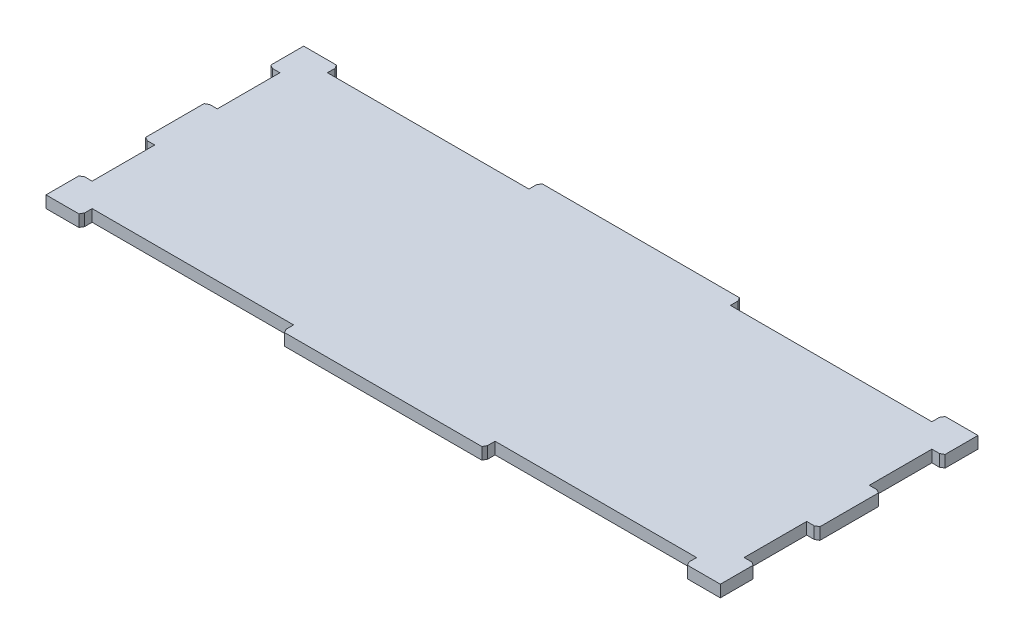
from build123d import *

# Parameters (mm, degrees)
SKETCH1_W             = 245.11
SKETCH1_H             = 93.653112922
BOSS_EXTRUDE1_DEPTH   = 4.318
CUT_EXTRUDE1_REACH    = 6.318
SKETCH2_W             = 4.064
SKETCH2_H             = 22.751037641
SKETCH2_W_2           = 73.236666667
SKETCH2_H_2           = 4.064
CHAMFER1_SIZE         = 0.762
CHAMFER1_SIZE2        = 1.319822715
CHAMFER1_PART_2_SIZE  = 0.762
CHAMFER1_PART_2_SIZE2 = 1.319822715
CHAMFER1_PART_3_SIZE  = 0.762
CHAMFER1_PART_3_SIZE2 = 1.319822715
CHAMFER1_PART_4_SIZE  = 0.762
CHAMFER1_PART_4_SIZE2 = 1.319822715
CHAMFER1_PART_5_SIZE  = 0.762
CHAMFER1_PART_5_SIZE2 = 1.319822715
CHAMFER1_PART_6_SIZE  = 0.762
CHAMFER1_PART_6_SIZE2 = 1.319822715
CHAMFER1_PART_7_SIZE  = 0.762
CHAMFER1_PART_7_SIZE2 = 1.319822715
CHAMFER1_PART_8_SIZE  = 0.762
CHAMFER1_PART_8_SIZE2 = 1.319822715
CHAMFER2_SIZE         = 0.762
CHAMFER2_SIZE2        = 1.319822715
CHAMFER2_PART_2_SIZE  = 0.762
CHAMFER2_PART_2_SIZE2 = 1.319822715
CHAMFER2_PART_3_SIZE  = 0.762
CHAMFER2_PART_3_SIZE2 = 1.319822715
CHAMFER2_PART_4_SIZE  = 0.762
CHAMFER2_PART_4_SIZE2 = 1.319822715
CHAMFER2_PART_5_SIZE  = 0.762
CHAMFER2_PART_5_SIZE2 = 1.319822715
CHAMFER2_PART_6_SIZE  = 0.762
CHAMFER2_PART_6_SIZE2 = 1.319822715
CHAMFER2_PART_7_SIZE  = 0.762
CHAMFER2_PART_7_SIZE2 = 1.319822715
CHAMFER2_PART_8_SIZE  = 0.762
CHAMFER2_PART_8_SIZE2 = 1.319822715


with BuildPart() as part:
    # Sketch1 → Boss-Extrude1 (new body)
    with BuildSketch(Plane(origin=(0, 0, 0), x_dir=(1, 0, 0), z_dir=(0, 1, 0))):
        Rectangle(SKETCH1_W, SKETCH1_H)
    extrude(amount=BOSS_EXTRUDE1_DEPTH)

    # Sketch2 → Cut-Extrude1 (cut, up to next)
    with BuildSketch(Plane(origin=(0, 4.318, 0), x_dir=(1, 0, 0), z_dir=(0, 1, 0)), mode=Mode.PRIVATE) as cut_extrude1_sk1:
        with Locations((-120.523, 22.751037641)):
            Rectangle(SKETCH2_W, SKETCH2_H)
    cut_extrude1_tool1 = extrude(cut_extrude1_sk1.sketch, amount=-CUT_EXTRUDE1_REACH, mode=Mode.PRIVATE) & part.part
    add(cut_extrude1_tool1.solids().sort_by_distance((-120.523, 4.318, -22.751038))[0], mode=Mode.SUBTRACT)
    # Sketch2 → Cut-Extrude1 (cut, up to next)
    with BuildSketch(Plane(origin=(0, 4.318, 0), x_dir=(1, 0, 0), z_dir=(0, 1, 0)), mode=Mode.PRIVATE) as cut_extrude1_sk2:
        with Locations((-73.236666666, -44.794556461)):
            Rectangle(SKETCH2_W_2, SKETCH2_H_2)
    cut_extrude1_tool2 = extrude(cut_extrude1_sk2.sketch, amount=-CUT_EXTRUDE1_REACH, mode=Mode.PRIVATE) & part.part
    add(cut_extrude1_tool2.solids().sort_by_distance((-73.236667, 4.318, 44.794556))[0], mode=Mode.SUBTRACT)
    # Sketch2 → Cut-Extrude1 (cut, up to next)
    with BuildSketch(Plane(origin=(0, 4.318, 0), x_dir=(1, 0, 0), z_dir=(0, 1, 0)), mode=Mode.PRIVATE) as cut_extrude1_sk3:
        with Locations((73.236666666, -44.794556461)):
            Rectangle(SKETCH2_W_2, SKETCH2_H_2)
    cut_extrude1_tool3 = extrude(cut_extrude1_sk3.sketch, amount=-CUT_EXTRUDE1_REACH, mode=Mode.PRIVATE) & part.part
    add(cut_extrude1_tool3.solids().sort_by_distance((73.236667, 4.318, 44.794556))[0], mode=Mode.SUBTRACT)
    # Sketch2 → Cut-Extrude1 (cut, up to next)
    with BuildSketch(Plane(origin=(0, 4.318, 0), x_dir=(1, 0, 0), z_dir=(0, 1, 0)), mode=Mode.PRIVATE) as cut_extrude1_sk4:
        with Locations((-120.523, -22.751037641)):
            Rectangle(SKETCH2_W, SKETCH2_H)
    cut_extrude1_tool4 = extrude(cut_extrude1_sk4.sketch, amount=-CUT_EXTRUDE1_REACH, mode=Mode.PRIVATE) & part.part
    add(cut_extrude1_tool4.solids().sort_by_distance((-120.523, 4.318, 22.751038))[0], mode=Mode.SUBTRACT)
    # Sketch2 → Cut-Extrude1 (cut, up to next)
    with BuildSketch(Plane(origin=(0, 4.318, 0), x_dir=(1, 0, 0), z_dir=(0, 1, 0)), mode=Mode.PRIVATE) as cut_extrude1_sk5:
        with Locations((-73.236666666, 44.794556461)):
            Rectangle(SKETCH2_W_2, SKETCH2_H_2)
    cut_extrude1_tool5 = extrude(cut_extrude1_sk5.sketch, amount=-CUT_EXTRUDE1_REACH, mode=Mode.PRIVATE) & part.part
    add(cut_extrude1_tool5.solids().sort_by_distance((-73.236667, 4.318, -44.794556))[0], mode=Mode.SUBTRACT)
    # Sketch2 → Cut-Extrude1 (cut, up to next)
    with BuildSketch(Plane(origin=(0, 4.318, 0), x_dir=(1, 0, 0), z_dir=(0, 1, 0)), mode=Mode.PRIVATE) as cut_extrude1_sk6:
        with Locations((73.236666666, 44.794556461)):
            Rectangle(SKETCH2_W_2, SKETCH2_H_2)
    cut_extrude1_tool6 = extrude(cut_extrude1_sk6.sketch, amount=-CUT_EXTRUDE1_REACH, mode=Mode.PRIVATE) & part.part
    add(cut_extrude1_tool6.solids().sort_by_distance((73.236667, 4.318, -44.794556))[0], mode=Mode.SUBTRACT)
    # Sketch2 → Cut-Extrude1 (cut, up to next)
    with BuildSketch(Plane(origin=(0, 4.318, 0), x_dir=(1, 0, 0), z_dir=(0, 1, 0)), mode=Mode.PRIVATE) as cut_extrude1_sk7:
        with Locations((120.523, 22.751037641)):
            Rectangle(SKETCH2_W, SKETCH2_H)
    cut_extrude1_tool7 = extrude(cut_extrude1_sk7.sketch, amount=-CUT_EXTRUDE1_REACH, mode=Mode.PRIVATE) & part.part
    add(cut_extrude1_tool7.solids().sort_by_distance((120.523, 4.318, -22.751038))[0], mode=Mode.SUBTRACT)
    # Sketch2 → Cut-Extrude1 (cut, up to next)
    with BuildSketch(Plane(origin=(0, 4.318, 0), x_dir=(1, 0, 0), z_dir=(0, 1, 0)), mode=Mode.PRIVATE) as cut_extrude1_sk8:
        with Locations((120.523, -22.751037641)):
            Rectangle(SKETCH2_W, SKETCH2_H)
    cut_extrude1_tool8 = extrude(cut_extrude1_sk8.sketch, amount=-CUT_EXTRUDE1_REACH, mode=Mode.PRIVATE) & part.part
    add(cut_extrude1_tool8.solids().sort_by_distance((120.523, 4.318, 22.751038))[0], mode=Mode.SUBTRACT)

    # Chamfer1
    chamfer1_edges = [part.edges().sort_by_distance(p)[0] for p in [
        (109.855, 2.159, -46.826556461),
    ]]
    chamfer1_side = [part.faces().sort_by_distance(p)[0] for p in [
        (116.205, 2.159, -46.826556461),
    ]]
    chamfer(chamfer1_edges, length=CHAMFER1_SIZE, length2=CHAMFER1_SIZE2, reference=chamfer1_side[0])

    # Chamfer1 part 2
    chamfer1_part_2_edges = [part.edges().sort_by_distance(p)[0] for p in [
        (-109.855, 2.159, 46.826556461),
    ]]
    chamfer1_part_2_side = [part.faces().sort_by_distance(p)[0] for p in [
        (-116.205, 2.159, 46.826556461),
    ]]
    chamfer(chamfer1_part_2_edges, length=CHAMFER1_PART_2_SIZE, length2=CHAMFER1_PART_2_SIZE2, reference=chamfer1_part_2_side[0])

    # Chamfer1 part 3
    chamfer1_part_3_edges = [part.edges().sort_by_distance(p)[0] for p in [
        (-36.618333333, 2.159, -46.826556461),
    ]]
    chamfer1_part_3_side = [part.faces().sort_by_distance(p)[0] for p in [
        (0, 2.159, -46.826556461),
    ]]
    chamfer(chamfer1_part_3_edges, length=CHAMFER1_PART_3_SIZE, length2=CHAMFER1_PART_3_SIZE2, reference=chamfer1_part_3_side[0])

    # Chamfer1 part 4
    chamfer1_part_4_edges = [part.edges().sort_by_distance(p)[0] for p in [
        (-122.555, 2.159, 11.37551882),
    ]]
    chamfer1_part_4_side = [part.faces().sort_by_distance(p)[0] for p in [
        (-122.555, 2.159, 0),
    ]]
    chamfer(chamfer1_part_4_edges, length=CHAMFER1_PART_4_SIZE, length2=CHAMFER1_PART_4_SIZE2, reference=chamfer1_part_4_side[0])

    # Chamfer1 part 5
    chamfer1_part_5_edges = [part.edges().sort_by_distance(p)[0] for p in [
        (122.555, 2.159, 34.126556461),
    ]]
    chamfer1_part_5_side = [part.faces().sort_by_distance(p)[0] for p in [
        (122.555, 2.159, 40.476556461),
    ]]
    chamfer(chamfer1_part_5_edges, length=CHAMFER1_PART_5_SIZE, length2=CHAMFER1_PART_5_SIZE2, reference=chamfer1_part_5_side[0])

    # Chamfer1 part 6
    chamfer1_part_6_edges = [part.edges().sort_by_distance(p)[0] for p in [
        (122.555, 2.159, -11.37551882),
    ]]
    chamfer1_part_6_side = [part.faces().sort_by_distance(p)[0] for p in [
        (122.555, 2.159, 0),
    ]]
    chamfer(chamfer1_part_6_edges, length=CHAMFER1_PART_6_SIZE, length2=CHAMFER1_PART_6_SIZE2, reference=chamfer1_part_6_side[0])

    # Chamfer1 part 7
    chamfer1_part_7_edges = [part.edges().sort_by_distance(p)[0] for p in [
        (36.618333333, 2.159, 46.826556461),
    ]]
    chamfer1_part_7_side = [part.faces().sort_by_distance(p)[0] for p in [
        (0, 2.159, 46.826556461),
    ]]
    chamfer(chamfer1_part_7_edges, length=CHAMFER1_PART_7_SIZE, length2=CHAMFER1_PART_7_SIZE2, reference=chamfer1_part_7_side[0])

    # Chamfer1 part 8
    chamfer1_part_8_edges = [part.edges().sort_by_distance(p)[0] for p in [
        (-122.555, 2.159, -34.126556461),
    ]]
    chamfer1_part_8_side = [part.faces().sort_by_distance(p)[0] for p in [
        (-122.555, 2.159, -40.476556461),
    ]]
    chamfer(chamfer1_part_8_edges, length=CHAMFER1_PART_8_SIZE, length2=CHAMFER1_PART_8_SIZE2, reference=chamfer1_part_8_side[0])

    # Chamfer2
    chamfer2_edges = [part.edges().sort_by_distance(p)[0] for p in [
        (36.618333333, 2.159, -46.826556461),
    ]]
    chamfer2_side = [part.faces().sort_by_distance(p)[0] for p in [
        (0.381, 2.159, -46.826556461),
    ]]
    chamfer(chamfer2_edges, length=CHAMFER2_SIZE, length2=CHAMFER2_SIZE2, reference=chamfer2_side[0])

    # Chamfer2 part 2
    chamfer2_part_2_edges = [part.edges().sort_by_distance(p)[0] for p in [
        (-36.618333333, 2.159, 46.826556461),
    ]]
    chamfer2_part_2_side = [part.faces().sort_by_distance(p)[0] for p in [
        (-0.381, 2.159, 46.826556461),
    ]]
    chamfer(chamfer2_part_2_edges, length=CHAMFER2_PART_2_SIZE, length2=CHAMFER2_PART_2_SIZE2, reference=chamfer2_part_2_side[0])

    # Chamfer2 part 3
    chamfer2_part_3_edges = [part.edges().sort_by_distance(p)[0] for p in [
        (-109.855, 2.159, -46.826556461),
    ]]
    chamfer2_part_3_side = [part.faces().sort_by_distance(p)[0] for p in [
        (-116.205, 2.159, -46.826556461),
    ]]
    chamfer(chamfer2_part_3_edges, length=CHAMFER2_PART_3_SIZE, length2=CHAMFER2_PART_3_SIZE2, reference=chamfer2_part_3_side[0])

    # Chamfer2 part 4
    chamfer2_part_4_edges = [part.edges().sort_by_distance(p)[0] for p in [
        (-122.555, 2.159, 34.126556461),
    ]]
    chamfer2_part_4_side = [part.faces().sort_by_distance(p)[0] for p in [
        (-122.555, 2.159, 40.476556461),
    ]]
    chamfer(chamfer2_part_4_edges, length=CHAMFER2_PART_4_SIZE, length2=CHAMFER2_PART_4_SIZE2, reference=chamfer2_part_4_side[0])

    # Chamfer2 part 5
    chamfer2_part_5_edges = [part.edges().sort_by_distance(p)[0] for p in [
        (122.555, 2.159, 11.37551882),
    ]]
    chamfer2_part_5_side = [part.faces().sort_by_distance(p)[0] for p in [
        (122.555, 2.159, 0.381),
    ]]
    chamfer(chamfer2_part_5_edges, length=CHAMFER2_PART_5_SIZE, length2=CHAMFER2_PART_5_SIZE2, reference=chamfer2_part_5_side[0])

    # Chamfer2 part 6
    chamfer2_part_6_edges = [part.edges().sort_by_distance(p)[0] for p in [
        (122.555, 2.159, -34.126556461),
    ]]
    chamfer2_part_6_side = [part.faces().sort_by_distance(p)[0] for p in [
        (122.555, 2.159, -40.476556461),
    ]]
    chamfer(chamfer2_part_6_edges, length=CHAMFER2_PART_6_SIZE, length2=CHAMFER2_PART_6_SIZE2, reference=chamfer2_part_6_side[0])

    # Chamfer2 part 7
    chamfer2_part_7_edges = [part.edges().sort_by_distance(p)[0] for p in [
        (109.855, 2.159, 46.826556461),
    ]]
    chamfer2_part_7_side = [part.faces().sort_by_distance(p)[0] for p in [
        (116.205, 2.159, 46.826556461),
    ]]
    chamfer(chamfer2_part_7_edges, length=CHAMFER2_PART_7_SIZE, length2=CHAMFER2_PART_7_SIZE2, reference=chamfer2_part_7_side[0])

    # Chamfer2 part 8
    chamfer2_part_8_edges = [part.edges().sort_by_distance(p)[0] for p in [
        (-122.555, 2.159, -11.37551882),
    ]]
    chamfer2_part_8_side = [part.faces().sort_by_distance(p)[0] for p in [
        (-122.555, 2.159, -0.381),
    ]]
    chamfer(chamfer2_part_8_edges, length=CHAMFER2_PART_8_SIZE, length2=CHAMFER2_PART_8_SIZE2, reference=chamfer2_part_8_side[0])


solid = part.part
